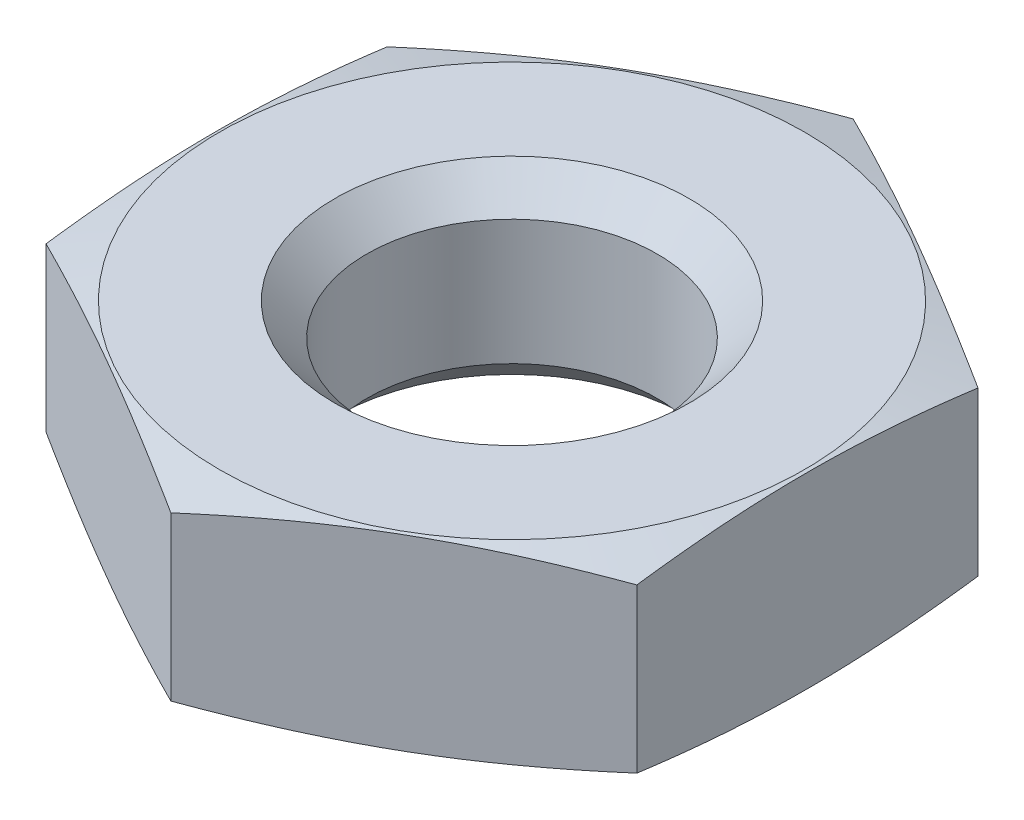
from build123d import *

# Parameters (mm, degrees)
SKIZZE2_W                            = 40
SKIZZE2_H                            = 40
SCHNITT_LINEAR_AUSTRAGEN1_DEPTH      = 4.2
SCHNITT_LINEAR_AUSTRAGEN1_DEPTH_BACK = 4.2


with BuildPart() as part:
    # Skizze1 → Rotation1 (revolve)
    with BuildSketch(Plane.XY):
        Polygon((0, 0), (4.95, 0), (10.921281292, -1.6), (4.95, -3.2), (0, -3.2), align=None)
    revolve(axis=Axis((0, -3.2, 0), (0, 1, 0)))

    # Skizze2 → Schnitt-Linear austragen1 (cut, two sides)
    with BuildSketch(Plane(origin=(0, 0, 0), x_dir=(1, 0, 0), z_dir=(0, 1, 0))) as schnitt_linear_austragen1_sk:
        Rectangle(SKIZZE2_W, SKIZZE2_H)
        Polygon((-5, -2.886751346), (0, -5.773502692), (5, -2.886751346), (5, 2.886751346), (0, 5.773502692), (-5, 2.886751346), align=None, mode=Mode.SUBTRACT)
    extrude(amount=SCHNITT_LINEAR_AUSTRAGEN1_DEPTH, mode=Mode.SUBTRACT)
    extrude(schnitt_linear_austragen1_sk.sketch, amount=-SCHNITT_LINEAR_AUSTRAGEN1_DEPTH_BACK, mode=Mode.SUBTRACT)

    # Skizze3 → Schnitt-Rotation1 (revolve, cut)
    with BuildSketch(Plane.XY):
        Polygon((0, 0), (3, 0), (2.4585, -0.5415), (2.4585, -2.6585), (3, -3.2), (0, -3.2), align=None)
    revolve(axis=Axis((0, -3.2, 0), (0, 1, 0)), mode=Mode.SUBTRACT)


solid = part.part
